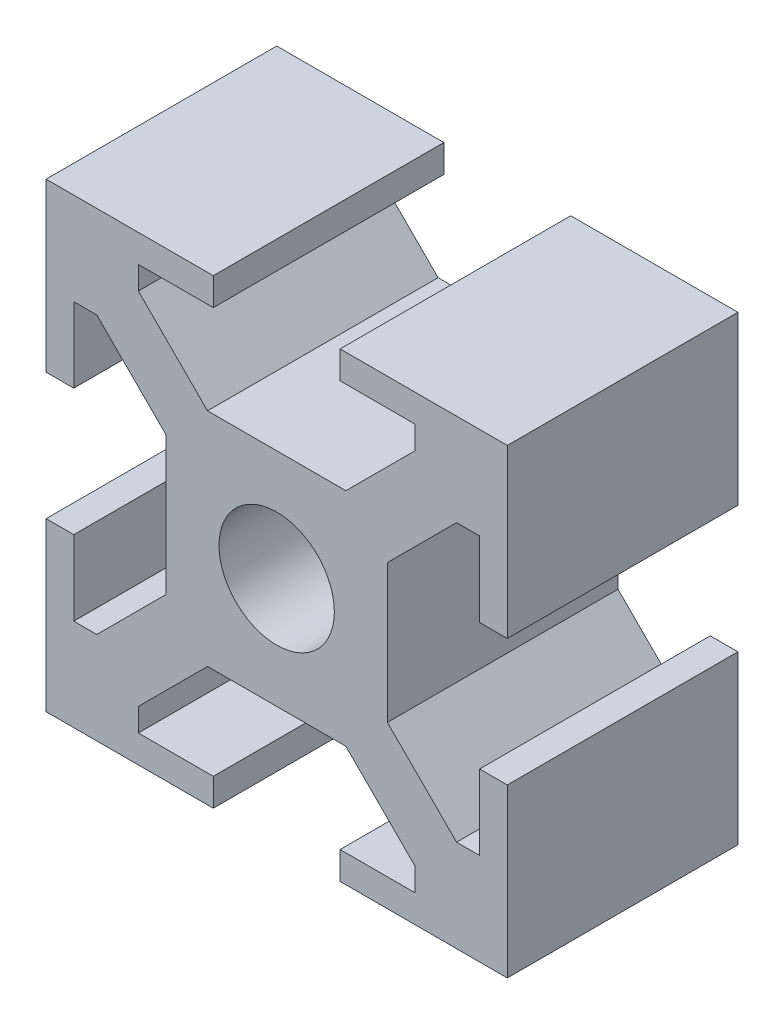
from build123d import *

# Parameters (mm, degrees)
ESQUISSE1_W             = 20
ESQUISSE1_H             = 20
BOSS_EXTRU_1_DEPTH      = 10
ESQUISSE2_W             = 1.2
ESQUISSE2_H             = 5.5
ESQUISSE2_W_2           = 5.5
ESQUISSE2_H_2           = 1.2
ENL_V_MAT_EXTRU_1_DEPTH = 11
ENL_V_MAT_EXTRU_2_DEPTH = 11
ESQUISSE4_R             = 2.5
ENL_V_MAT_EXTRU_3_DEPTH = 11


with BuildPart() as part:
    # Esquisse1 → Boss.-Extru.1 (new body)
    with BuildSketch(Plane.XY):
        with Locations((-12.505109137, -9.909560068)):
            Rectangle(ESQUISSE1_W, ESQUISSE1_H)
    extrude(amount=BOSS_EXTRU_1_DEPTH)

    # Esquisse2 → Enlèv. mat.-Extru.1 (cut, through all)
    with BuildSketch(Plane.XY.offset(10)):
        with Locations((-21.905109137, -9.909560068)):
            Rectangle(ESQUISSE2_W, ESQUISSE2_H)
        with Locations((-12.505109137, -0.509560068)):
            Rectangle(ESQUISSE2_W_2, ESQUISSE2_H_2)
        with Locations((-3.105109137, -9.909560068)):
            Rectangle(ESQUISSE2_W, ESQUISSE2_H)
        with Locations((-12.505109137, -19.309560068)):
            Rectangle(ESQUISSE2_W_2, ESQUISSE2_H_2)
    extrude(amount=-ENL_V_MAT_EXTRU_1_DEPTH, mode=Mode.SUBTRACT)

    # Esquisse3 → Enlèv. mat.-Extru.2 (cut, through all)
    with BuildSketch(Plane.XY.offset(10)):
        Polygon((-21.305109137, -15.909560068), (-20.305109137, -15.909560068), (-17.305109137, -12.909560068), (-17.305109137, -6.909560068), (-20.305109137, -3.909560068), (-21.305109137, -3.909560068), align=None)
        Polygon((-18.505109137, -1.109560068), (-6.505109137, -1.109560068), (-6.505109137, -2.109560068), (-9.505109137, -5.109560068), (-15.505109137, -5.109560068), (-18.505109137, -2.109560068), align=None)
        Polygon((-3.705109137, -3.909560068), (-4.705109137, -3.909560068), (-7.705109137, -6.909560068), (-7.705109137, -12.909560068), (-4.705109137, -15.909560068), (-3.705109137, -15.909560068), align=None)
        Polygon((-6.505109137, -18.709560068), (-18.505109137, -18.709560068), (-18.505109137, -17.709560068), (-15.505109137, -14.709560068), (-9.505109137, -14.709560068), (-6.505109137, -17.709560068), align=None)
    extrude(amount=-ENL_V_MAT_EXTRU_2_DEPTH, mode=Mode.SUBTRACT)

    # Esquisse4 → Enlèv. mat.-Extru.3 (cut, through all)
    with BuildSketch(Plane.XY.offset(10)):
        with Locations((-12.505109137, -9.909560068)):
            Circle(ESQUISSE4_R)
    extrude(amount=-ENL_V_MAT_EXTRU_3_DEPTH, mode=Mode.SUBTRACT)


solid = part.part
